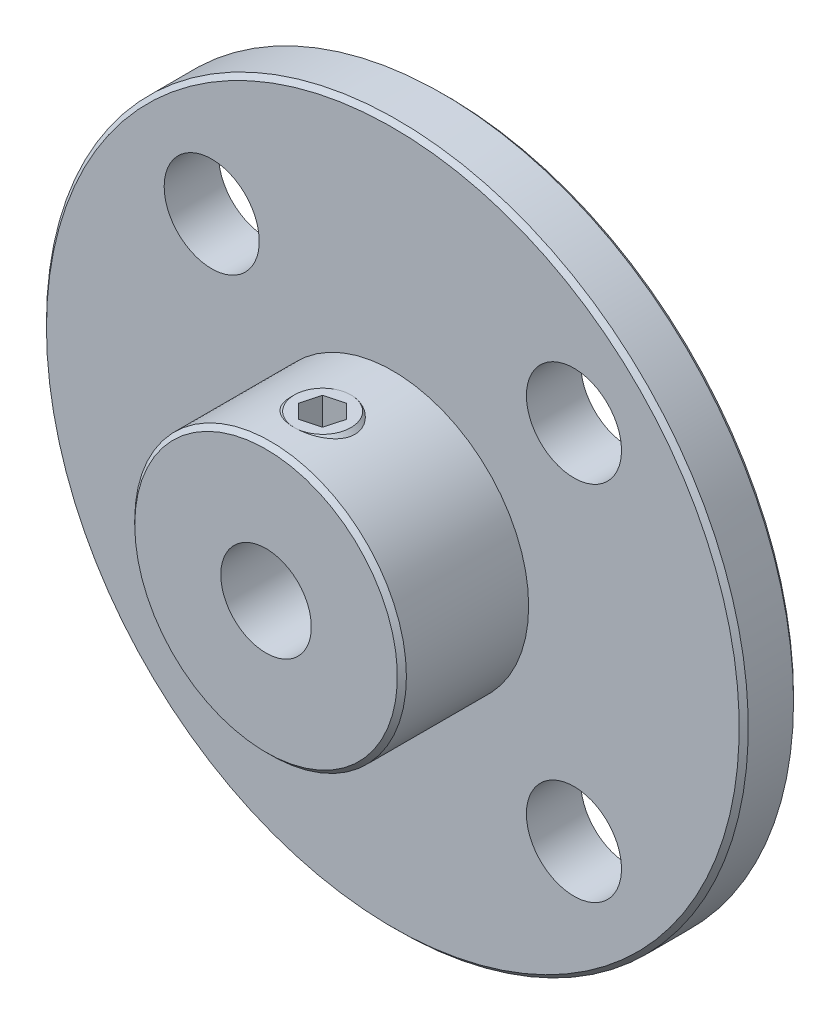
from build123d import *

# Parameters (mm, degrees)
SKETCH2_R           = 1.25
CUT_EXTRUDE1_DEPTH  = 24.334523779
SKETCH3_R           = 2.1
CUT_EXTRUDE2_DEPTH  = 24.334523813
CIRPATTERN1_COUNT   = 4
CHAMFER1_SIZE       = 0.2
SKETCH4_R           = 1.5
BOSS_EXTRUDE1_DEPTH = 4.5
CHAMFER2_SIZE       = 0.25
CUT_EXTRUDE3_DEPTH  = 2


with BuildPart() as part:
    # Sketch1 → Revolve1 (revolve)
    with BuildSketch(Plane(origin=(0, 0, 0), x_dir=(1, 0, 0), z_dir=(0, 1, 0))):
        Polygon((2, 0), (2, -8), (6, -8), (6, -2.4), (15.5, -2.4), (15.5, 0), align=None)
    revolve(axis=Axis((0, 0, -122.457916377), (0, 0, 1)))

    # Sketch2 → Cut-Extrude1 (cut, through all)
    with BuildSketch(Plane(origin=(0, 0, 0), x_dir=(1, 0, 0), z_dir=(0, 1, 0))):
        with Locations((0, -5.5)):
            Circle(SKETCH2_R)
    extrude(amount=CUT_EXTRUDE1_DEPTH, mode=Mode.SUBTRACT)

    # Sketch3 → Cut-Extrude2 (cut, through all)
    with BuildSketch(Plane(origin=(0, 0, 0), x_dir=(-1, 0, 0), z_dir=(0, 0, -1))):
        with Locations((8, 8)):
            Circle(SKETCH3_R)
    cut_extrude2 = extrude(amount=-CUT_EXTRUDE2_DEPTH, mode=Mode.SUBTRACT)

    # CirPattern1: Cut-Extrude2 ×4 about axis
    cirpattern1_axis = Axis((0, 0, -7.656261881), (0, 0, 1))
    for i in range(1, CIRPATTERN1_COUNT):
        add(cut_extrude2.rotate(cirpattern1_axis, i * 360 / CIRPATTERN1_COUNT), mode=Mode.SUBTRACT)

    # Chamfer1
    chamfer1_edges = [part.edges().sort_by_distance(p)[0] for p in [
        (-6, 0, 8),
        (-15.5, 0, 2.4),
        (-15.5, 0, 0),
    ]]
    chamfer(chamfer1_edges, length=CHAMFER1_SIZE)


with BuildPart() as body_2:
    # Sketch4 → Boss-Extrude1 (new body)
    with BuildSketch(Plane(origin=(0, 1.5, 0), x_dir=(1, 0, 0), z_dir=(0, 1, 0))):
        with Locations((0, -5.5)):
            Circle(SKETCH4_R)
    extrude(amount=BOSS_EXTRUDE1_DEPTH)

    # Chamfer2
    chamfer2_edges = [body_2.edges().sort_by_distance(p)[0] for p in [
        (-1.5, 6, 5.5),
    ]]
    chamfer(chamfer2_edges, length=CHAMFER2_SIZE)

    # Sketch5 → Cut-Extrude3 (cut)
    with BuildSketch(Plane(origin=(0, 6, 0), x_dir=(1, 0, 0), z_dir=(0, 1, 0))):
        Polygon((0.837023085, -5.27775609), (0.22604267, -4.66399479), (-0.610980415, -4.8862387), (-0.837023085, -5.72224391), (-0.22604267, -6.33600521), (0.610980415, -6.1137613), align=None)
    extrude(amount=-CUT_EXTRUDE3_DEPTH, mode=Mode.SUBTRACT)


solid = Compound([part.part, body_2.part])
